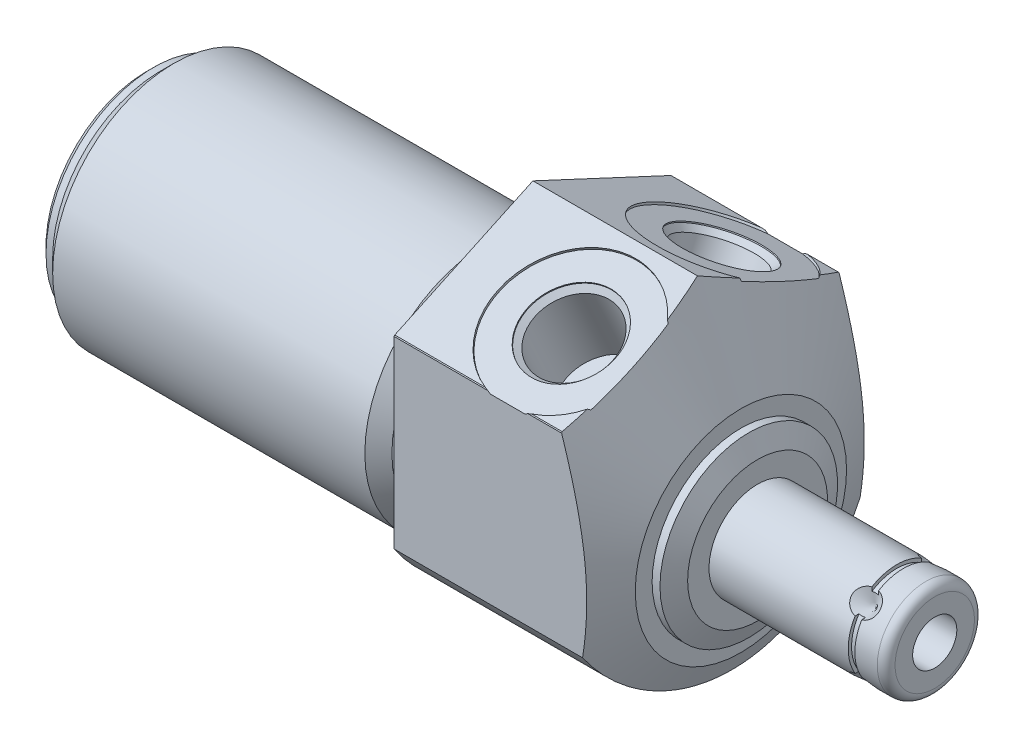
from build123d import *

# Parameters (mm, degrees)
SKETCH1_R           = 25.4
EXTRUDE1_DEPTH      = 25.7048
EXTRUDE1_DEPTH_BACK = 44.1452
CUT_EXTRUDE1_REACH  = 46.145
SKETCH2_R           = 25.4
SKETCH2_R_2         = 13.8684
CUT_EXTRUDE3_REACH  = 71.85
SKETCH4_R           = 25.4
CHAMFER1_SIZE       = 0.762
CIRPATTERN1_COUNT   = 4
SKETCH21_W          = 0.762
SKETCH21_H          = 0.381


with BuildPart() as part:
    # Sketch1 → Extrude1 (new body, two sides)
    with BuildSketch(Plane(origin=(0, 0, 0), x_dir=(0, 0, -1), z_dir=(1, 0, 0))) as extrude1_sk:
        Circle(SKETCH1_R)
    extrude(amount=EXTRUDE1_DEPTH)
    extrude(extrude1_sk.sketch, amount=-EXTRUDE1_DEPTH_BACK)

    # Sketch2 → Cut-Extrude1 (cut, up to next)
    with BuildSketch(Plane(origin=(0, 0, 0), x_dir=(0, 0, -1), z_dir=(1, 0, 0)), mode=Mode.PRIVATE) as cut_extrude1_sk1:
        Circle(SKETCH2_R)
        with Locations((0, -4.7498)):
            Circle(SKETCH2_R_2, mode=Mode.SUBTRACT)
    cut_extrude1_tool1 = extrude(cut_extrude1_sk1.sketch, amount=-CUT_EXTRUDE1_REACH, mode=Mode.PRIVATE) & part.part
    add(cut_extrude1_tool1.solids().sort_by_distance((0, 0, 24.68158))[0], mode=Mode.SUBTRACT)

    # Sketch4 → Cut-Extrude3 (cut, up to next)
    with BuildSketch(Plane.ZY.offset(-25.7048), mode=Mode.PRIVATE) as cut_extrude3_sk1:
        Circle(SKETCH4_R)
        with BuildLine():
            Line((15.875, -10.530283709), (15.875, 10.530283709))
            ThreePointArc((15.875, 10.530283709), (15.839063031, 10.584261065), (15.802942532, 10.638115779))
            Line((15.802942532, 10.638115779), (0, 18.007148903))
            Line((0, 18.007148903), (-15.802942532, 10.638115779))
            ThreePointArc((-15.802942532, 10.638115779), (-15.839063031, 10.584261065), (-15.875, 10.530283709))
            Line((-15.875, 10.530283709), (-15.875, -10.530283709))
            ThreePointArc((-15.875, -10.530283709), (0, -19.05), (15.875, -10.530283709))
        make_face(mode=Mode.SUBTRACT)
    cut_extrude3_tool1 = extrude(cut_extrude3_sk1.sketch, amount=CUT_EXTRUDE3_REACH, mode=Mode.PRIVATE) & part.part
    add(cut_extrude3_tool1.solids().sort_by_distance((25.7048, 0, -24.68158))[0], mode=Mode.SUBTRACT)

    # Sketch6 → Cut-Revolve2 (revolve, cut)
    with BuildSketch(Plane.XY, mode=Mode.PRIVATE) as cut_revolve2_sk:
        Polygon((18.823988023, 18.007148903), (23.7998, 7.336485684), (23.7998, 5.4102), (24.698041766, 5.4102), (25.7048, 3.2512), (25.7048, 18.007148903), align=None)
    revolve(cut_revolve2_sk.sketch.rotate(Axis((1.987224567, -4.7498, 0), (1, 0, 0)), 90), axis=Axis((1.987224567, -4.7498, 0), (1, 0, 0)), mode=Mode.SUBTRACT)  # turned: the seam where the file's is

    # S2D0002 → Cut-Revolve3 (revolve, cut)
    with BuildSketch(Plane(origin=(13.0048, 13.712414668, 8.609072086), x_dir=(0, 0.422618262, -0.906307787), z_dir=(1, 0, 0))):
        Polygon((5.0165, 0), (8.255, 0), (8.255, 0.254), (0, 0.254), (0, -9.398), (4.4196, -9.398), (4.4196, -0.7239), (5.0165, -0.127), align=None)
    cut_revolve3 = revolve(axis=Axis((13.0048, 2.110224902, 3.198882147), (0, 0.906307787, 0.422618262)), mode=Mode.SUBTRACT)

    # Mirror1: Cut-Revolve3 across plane
    add(cut_revolve3.mirror(Plane.XY), mode=Mode.SUBTRACT)

    # Sketch10 → Cut-Revolve6 (revolve, cut)
    with BuildSketch(Plane.XY, mode=Mode.PRIVATE) as cut_revolve6_sk:
        Polygon((0, 9.1186), (0, 7.5692), (-3.81, 7.5692), (-5.3594, 9.1186), align=None)
    revolve(cut_revolve6_sk.sketch.rotate(Axis((-5.09397, -4.7498, 0), (1, 0, 0)), 90), axis=Axis((-5.09397, -4.7498, 0), (1, 0, 0)), mode=Mode.SUBTRACT)  # turned: the seam where the file's is

    # Sketch12 → Cut-Revolve8 (revolve, cut)
    with BuildSketch(Plane.XY, mode=Mode.PRIVATE) as cut_revolve8_sk:
        Polygon((-44.1452, 9.1186), (-44.1452, 7.5692), (-42.6212, 7.5692), (-41.0718, 9.1186), align=None)
    revolve(cut_revolve8_sk.sketch.rotate(Axis((-50.92827, -4.7498, 0), (1, 0, 0)), 90), axis=Axis((-50.92827, -4.7498, 0), (1, 0, 0)), mode=Mode.SUBTRACT)  # turned: the seam where the file's is

    # Chamfer1
    chamfer1_edges = [part.edges().sort_by_distance(p)[0] for p in [
        (-44.1452, -4.7498, -12.319),
    ]]
    chamfer(chamfer1_edges, length=CHAMFER1_SIZE)

    # Sketch13 → Revolve1 (revolve)
    with BuildSketch(Plane.XY, mode=Mode.PRIVATE) as revolve1_sk:
        with BuildLine():
            Line((25.7048, -4.7498), (45.974, -4.7498))
            Line((45.974, -4.7498), (45.974, -9.29005))
            ThreePointArc((45.974, -9.29005), (45.67642049, -10.00847049), (44.958, -10.30605))
            Line((44.958, -10.30605), (25.7048, -10.30605))
            Line((25.7048, -10.30605), (25.7048, -4.7498))
        make_face()
    revolve(revolve1_sk.sketch.rotate(Axis((4.7498, -4.7498, 0), (1, 0, 0)), 270), axis=Axis((4.7498, -4.7498, 0), (1, 0, 0)))  # turned: the seam where the file's is

    # S2D0001 → Cut-Revolve9 (revolve, cut)
    with BuildSketch(Plane.XY, mode=Mode.PRIVATE) as cut_revolve9_sk:
        Polygon((45.974, -2.2225), (35.814, -2.2225), (34.295444958, -4.7498), (45.974, -4.7498), align=None)
    revolve(cut_revolve9_sk.sketch.rotate(Axis((-2.8067, -4.7498, 0), (-1, 0, 0)), 270), axis=Axis((-2.8067, -4.7498, 0), (-1, 0, 0)), mode=Mode.SUBTRACT)  # turned: the seam where the file's is

    # Sketch16 → Cut-Revolve10 (revolve, cut)
    with BuildSketch(Plane(origin=(0, -8.108415789, 3.358615789), x_dir=(1, 0, 0), z_dir=(0, -0.707106781, -0.707106781)), mode=Mode.PRIVATE) as cut_revolve10_sk:
        Polygon((42.0116, -10.30605), (40.4241, -10.30605), (42.0116, -8.71855), align=None)
    cut_revolve10 = revolve(cut_revolve10_sk.sketch.rotate(Axis((42.0116, -5.648535273, 0.898735273), (0, -0.707106781, 0.707106781)), 270), axis=Axis((42.0116, -5.648535273, 0.898735273), (0, -0.707106781, 0.707106781)), mode=Mode.SUBTRACT)  # turned: the seam where the file's is

    # CirPattern1: Cut-Revolve10 ×4 about axis
    cirpattern1_axis = Axis((4.7498, -4.7498, 0), (-1, 0, 0))
    for i in range(1, CIRPATTERN1_COUNT):
        add(cut_revolve10.rotate(cirpattern1_axis, i * 360 / CIRPATTERN1_COUNT), mode=Mode.SUBTRACT)

    # Sketch21 → Cut-Revolve11 (revolve, cut)
    with BuildSketch(Plane.XY, mode=Mode.PRIVATE) as cut_revolve11_sk:
        with Locations((42.0116, 0.61595)):
            Rectangle(SKETCH21_W, SKETCH21_H)
    revolve(cut_revolve11_sk.sketch.rotate(Axis((23.873488058, -4.7498, 0), (1, 0, 0)), 90), axis=Axis((23.873488058, -4.7498, 0), (1, 0, 0)), mode=Mode.SUBTRACT)  # turned: the seam where the file's is


solid = part.part
